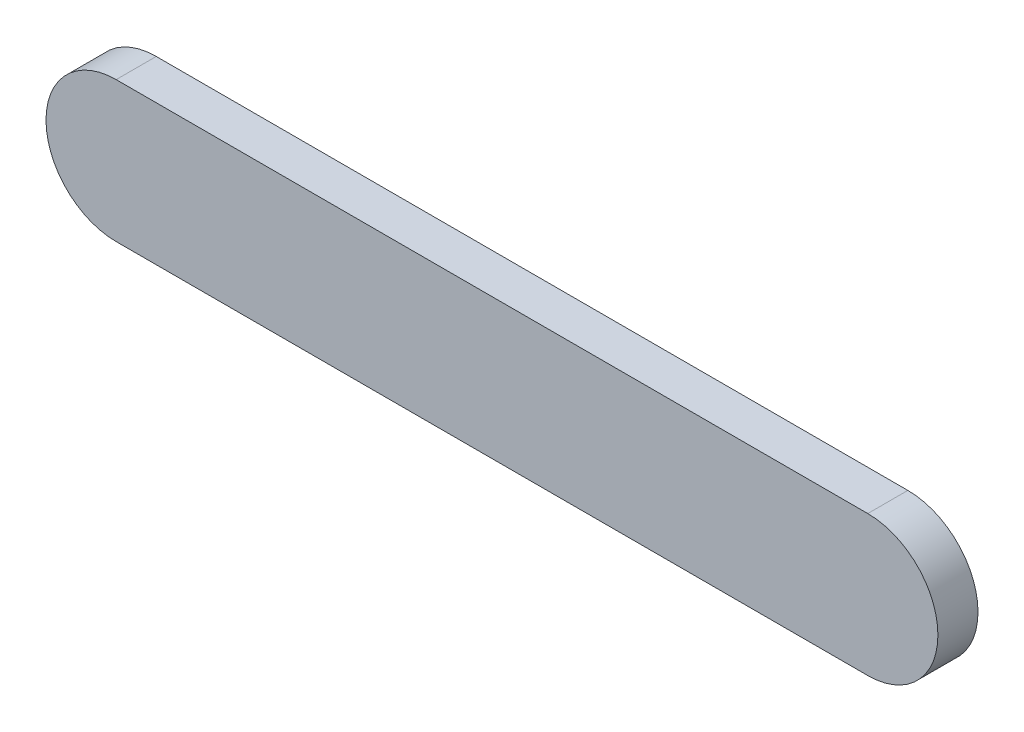
from build123d import *

# Parameters (mm, degrees)
EXTRUDE_1_DEPTH = 12


with BuildPart() as part:
    # 草图1 → 凸台-拉伸1 (new body)
    with BuildSketch(Plane.XY):
        with BuildLine():
            Line((-112.5, 21), (112.5, 21))
            ThreePointArc((112.5, 21), (133.5, 0), (112.5, -21))
            Line((112.5, -21), (-112.5, -21))
            ThreePointArc((-112.5, -21), (-133.5, 0), (-112.5, 21))
        make_face()
    extrude(amount=EXTRUDE_1_DEPTH)


solid = part.part
